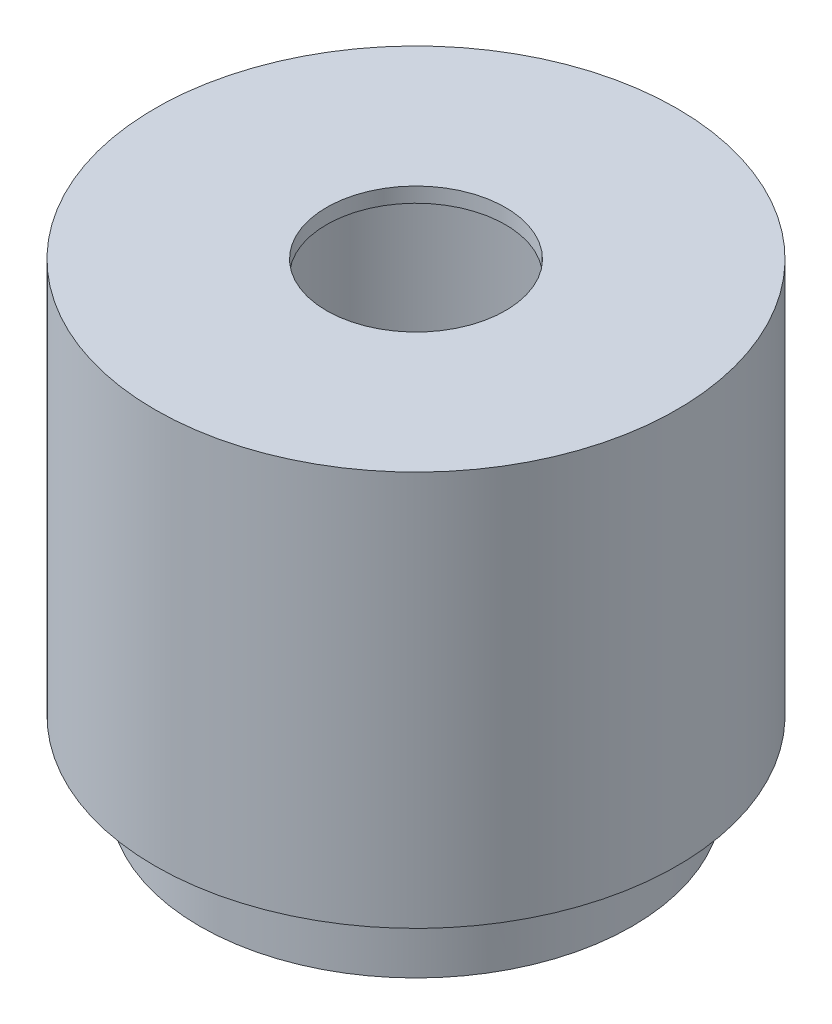
from build123d import *

# Parameters (mm, degrees)
SKETCH1_R           = 17.5
SKETCH1_R_2         = 12
BOSS_EXTRUDE1_DEPTH = 26.5
SKETCH2_R           = 12
SKETCH2_R_2         = 6
BOSS_EXTRUDE2_DEPTH = 1
SKETCH3_R           = 14.5
SKETCH3_R_2         = 12
BOSS_EXTRUDE3_DEPTH = 5


with BuildPart() as part:
    # Sketch1 → Boss-Extrude1 (new body)
    with BuildSketch(Plane(origin=(0, 0, 0), x_dir=(1, 0, 0), z_dir=(0, 1, 0))):
        Circle(SKETCH1_R)
        Circle(SKETCH1_R_2, mode=Mode.SUBTRACT)
    extrude(amount=BOSS_EXTRUDE1_DEPTH)

    # Sketch2 → Boss-Extrude2 (add)
    with BuildSketch(Plane(origin=(0, 26.5, 0), x_dir=(1, 0, 0), z_dir=(0, 1, 0))):
        Circle(SKETCH2_R)
        Circle(SKETCH2_R_2, mode=Mode.SUBTRACT)
    extrude(amount=-BOSS_EXTRUDE2_DEPTH)

    # Sketch3 → Boss-Extrude3 (add)
    with BuildSketch(Plane.XZ):
        Circle(SKETCH3_R)
        Circle(SKETCH3_R_2, mode=Mode.SUBTRACT)
    extrude(amount=BOSS_EXTRUDE3_DEPTH)


solid = part.part
